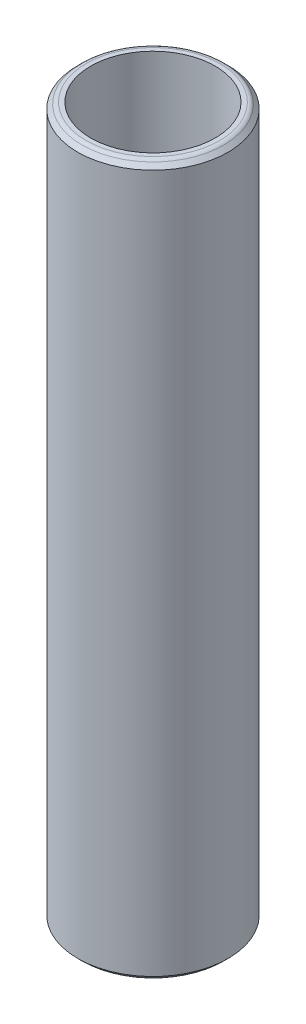
from build123d import *

# Parameters (mm, degrees)
SKETCH1_R           = 3.175
BOSS_EXTRUDE2_DEPTH = 30
CHAMFER1_SIZE       = 0.25
CHAMFER2_SIZE       = 0.25
SKETCH10_R          = 2.632684592
CUT_EXTRUDE2_DEPTH  = 34
FILLET2_R           = 0.25
FILLET3_R           = 0.25


with BuildPart() as part:
    # Sketch1 → Boss-Extrude2 (new body)
    with BuildSketch(Plane(origin=(0, 0, 0), x_dir=(1, 0, 0), z_dir=(0, 1, 0))):
        Circle(SKETCH1_R)
    extrude(amount=BOSS_EXTRUDE2_DEPTH)

    # Chamfer1
    chamfer1_edges = [part.edges().sort_by_distance(p)[0] for p in [
        (-3.175, 30, 0),
    ]]
    chamfer(chamfer1_edges, length=CHAMFER1_SIZE)

    # Chamfer2
    chamfer2_edges = [part.edges().sort_by_distance(p)[0] for p in [
        (-3.175, 0, 0),
    ]]
    chamfer(chamfer2_edges, length=CHAMFER2_SIZE)

    # Sketch10 → Cut-Extrude2 (cut)
    with BuildSketch(Plane(origin=(0, 0, 0), x_dir=(1, 0, 0), z_dir=(0, 1, 0))):
        Circle(SKETCH10_R)
    extrude(amount=CUT_EXTRUDE2_DEPTH, mode=Mode.SUBTRACT)

    # Fillet2
    fillet2_edges = [part.edges().sort_by_distance(p)[0] for p in [
        (-2.925, 30, 0),
    ]]
    fillet(fillet2_edges, radius=FILLET2_R)

    # Fillet3
    fillet3_edges = [part.edges().sort_by_distance(p)[0] for p in [
        (-2.925, 0, 0),
    ]]
    fillet(fillet3_edges, radius=FILLET3_R)


solid = part.part
